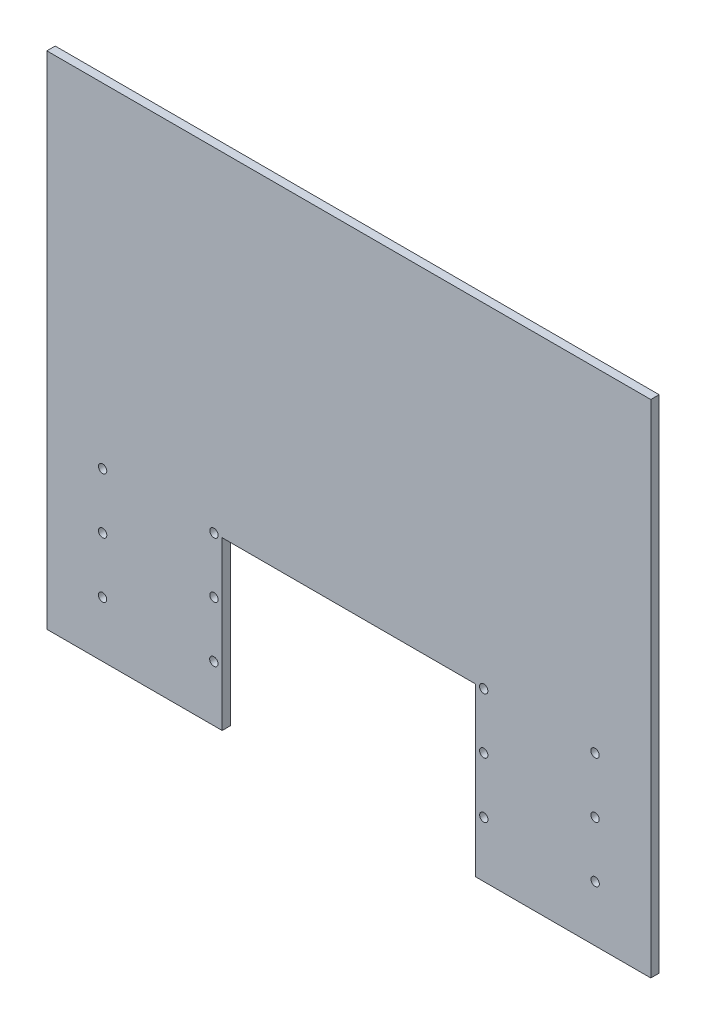
from build123d import *

# Parameters (mm, degrees)
SKETCH_1_R      = 0.75
EXTRUDE_2_DEPTH = 1.5


with BuildPart() as part:
    # 草图1 → 凸台-拉伸2 (new body)
    with BuildSketch(Plane.XY):
        Polygon((22.56703567, -52.430150394), (22.56703567, -22.430150394), (-22.93296433, -22.430150394), (-22.93296433, -52.430150394), (-54.43296433, -52.430150394), (-54.43296433, 37.569849606), (54.06703567, 37.569849606), (54.06703567, -52.430150394), align=None)
        with Locations((-44.413268249, -22.430150394)):
            Circle(SKETCH_1_R, mode=Mode.SUBTRACT)
        with Locations((-24.413268249, -22.430150394)):
            Circle(SKETCH_1_R, mode=Mode.SUBTRACT)
        with Locations((-24.43296433, -42.430150394)):
            Circle(SKETCH_1_R, mode=Mode.SUBTRACT)
        with Locations((-24.413268249, -32.430150394)):
            Circle(SKETCH_1_R, mode=Mode.SUBTRACT)
        with Locations((-44.413268249, -32.430150394)):
            Circle(SKETCH_1_R, mode=Mode.SUBTRACT)
        with Locations((-44.43296433, -42.430150394)):
            Circle(SKETCH_1_R, mode=Mode.SUBTRACT)
        with Locations((24.06703567, -42.430150394)):
            Circle(SKETCH_1_R, mode=Mode.SUBTRACT)
        with Locations((44.06703567, -42.430150394)):
            Circle(SKETCH_1_R, mode=Mode.SUBTRACT)
        with Locations((44.047339589, -32.430150394)):
            Circle(SKETCH_1_R, mode=Mode.SUBTRACT)
        with Locations((24.047339589, -32.430150394)):
            Circle(SKETCH_1_R, mode=Mode.SUBTRACT)
        with Locations((24.047339589, -22.430150394)):
            Circle(SKETCH_1_R, mode=Mode.SUBTRACT)
        with Locations((44.047339589, -22.430150394)):
            Circle(SKETCH_1_R, mode=Mode.SUBTRACT)
    extrude(amount=EXTRUDE_2_DEPTH)


solid = part.part
